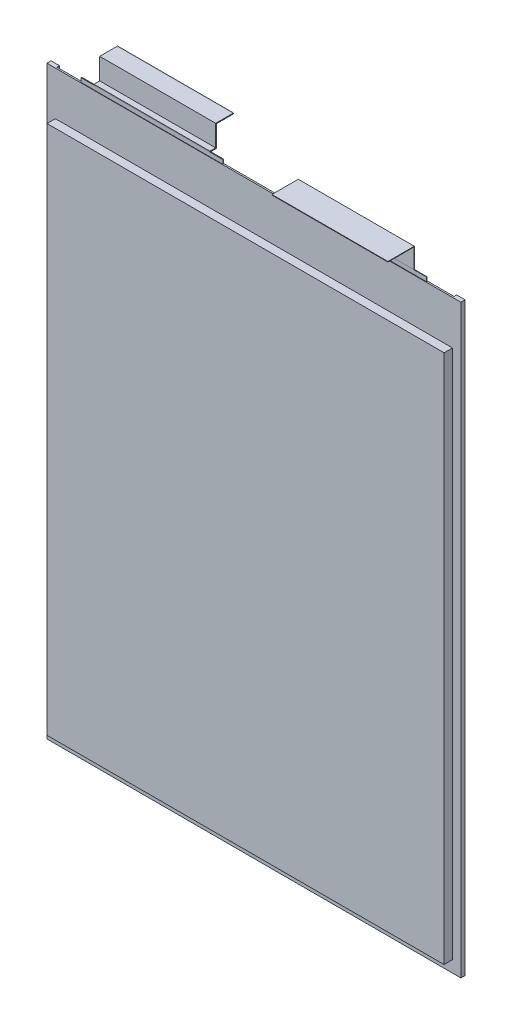
from build123d import *

# Parameters (mm, degrees)
SKETCH1_W                    = 160.6
SKETCH1_H                    = 227
INSULATION_DEPTH             = 0.3
INSULATION_DEPTH_BACK        = 0.3
SKETCH2_W                    = 154
SKETCH2_H                    = 205.5
MAIN_BODY_DEPTH              = 3.55
MAIN_BODY_DEPTH_BACK         = 3.55
SIDE_FOLDS_DEPTH             = 1.016
SKETCH6_W                    = 55
SKETCH6_H                    = 18.6
NEGATIVE_TAB_BASE_DEPTH      = 0.1
NEGATIVE_TAB_BASE_DEPTH_BACK = 0.1
SKETCH7_W                    = 55
SKETCH7_H                    = 18.6
POSITIVE_TAB_BASE_DEPTH      = 0.15
POSITIVE_TAB_BASE_DEPTH_BACK = 0.15
SKETCH113_W                  = 0.2
SKETCH113_H                  = 45
NEGATIVE_TAB_DEPTH           = 31.160222221
SKETCH113_ON_SEGMENT_2_W     = 0.2
SKETCH113_ON_SEGMENT_2_H     = 45
NEGATIVE_TAB_2_DEPTH         = 33.621222221
SKETCH110_W                  = 0.3
SKETCH110_H                  = 45
POSITIVE_TAB_DEPTH           = 23.650499994
SKETCH110_ON_SEGMENT_2_W     = 0.3
SKETCH110_ON_SEGMENT_2_H     = 45
POSITIVE_TAB_2_DEPTH         = 49.236449989
SKETCH110_ON_SEGMENT_3_W     = 0.3
SKETCH110_ON_SEGMENT_3_H     = 45
POSITIVE_TAB_3_DEPTH         = 55.260999989
SKETCH110_ON_SEGMENT_4_W     = 0.3
SKETCH110_ON_SEGMENT_4_H     = 45
POSITIVE_TAB_4_DEPTH         = 31.122574994
SKETCH110_ON_SEGMENT_5_W     = 0.3
SKETCH110_ON_SEGMENT_5_H     = 45
POSITIVE_TAB_5_DEPTH         = 1.15


with BuildPart() as part:
    # Sketch1 → Insulation (new, two sides)
    with BuildSketch(Plane.XY) as insulation_sk:
        Rectangle(SKETCH1_W, SKETCH1_H)
    extrude(amount=INSULATION_DEPTH)
    extrude(insulation_sk.sketch, amount=-INSULATION_DEPTH_BACK)

    # Sketch2 → Main Body (add, two sides)
    with BuildSketch(Plane.XY) as main_body_sk:
        with Locations((0, -6.25)):
            Rectangle(SKETCH2_W, SKETCH2_H)
    extrude(amount=MAIN_BODY_DEPTH)
    extrude(main_body_sk.sketch, amount=-MAIN_BODY_DEPTH_BACK)

    # Sketch5 → Side Folds (add)
    with BuildSketch(Plane(origin=(0, 0, -0.3), x_dir=(-1, 0, 0), z_dir=(0, 0, -1))):
        Polygon((-77, -109), (-77, 96.5), (-77, 113.5), (-80.3, 113.5), (-80.3, -113.5), (-77, -113.5), align=None)
        Polygon((77, 113.5), (77, 96.5), (77, -109), (77, -113.5), (80.3, -113.5), (80.3, 113.5), align=None)
    extrude(amount=SIDE_FOLDS_DEPTH)

    # Sketch6 → Negative Tab Base (add, two sides)
    with BuildSketch(Plane.XY) as negative_tab_base_sk:
        with Locations((39.3, 105.8)):
            Rectangle(SKETCH6_W, SKETCH6_H)
    extrude(amount=NEGATIVE_TAB_BASE_DEPTH)
    extrude(negative_tab_base_sk.sketch, amount=-NEGATIVE_TAB_BASE_DEPTH_BACK)

    # Sketch7 → Positive Tab Base (add, two sides)
    with BuildSketch(Plane.XY) as positive_tab_base_sk:
        with Locations((-39.7, 105.8)):
            Rectangle(SKETCH7_W, SKETCH7_H)
    extrude(amount=POSITIVE_TAB_BASE_DEPTH)
    extrude(positive_tab_base_sk.sketch, amount=-POSITIVE_TAB_BASE_DEPTH_BACK)


with BuildPart() as body_2:
    # Sketch113 → Negative Tab (new body)
    with BuildSketch(Plane(origin=(39.3, 115.1, 0), x_dir=(0, 0, -1), z_dir=(0, 1, 0))):
        Rectangle(SKETCH113_W, SKETCH113_H)
    extrude(amount=NEGATIVE_TAB_DEPTH)

    # Negative Tab mitre 1
    split(bisect_by=Plane(origin=(39.3, 122.76, 0), x_dir=(1, 0, 0), z_dir=(0, -0.707106781, -0.707106781)), keep=Keep.TOP)


with BuildPart() as body_3:
    # Sketch113 on segment 2 (carried to segment 2) → Negative Tab 2 (new body)
    with BuildSketch(Plane(origin=(39.3, 122.76, -23.500222221), x_dir=(0, 1, 0), z_dir=(0, 0, 1))):
        Rectangle(SKETCH113_ON_SEGMENT_2_W, SKETCH113_ON_SEGMENT_2_H)
    extrude(amount=NEGATIVE_TAB_2_DEPTH)

    # Negative Tab 2 mitre 1
    split(bisect_by=Plane(origin=(39.3, 122.76, 0), x_dir=(-1, 0, 0), z_dir=(0, 0.707106781, 0.707106781)), keep=Keep.TOP)


with BuildPart() as body_4:
    # Sketch110 → Positive Tab (new body)
    with BuildSketch(Plane(origin=(-39.7, 115.1, 0), x_dir=(0, 0, -1), z_dir=(0, 1, 0))):
        Rectangle(SKETCH110_W, SKETCH110_H)
    extrude(amount=POSITIVE_TAB_DEPTH)

    # Positive Tab mitre 1
    split(bisect_by=Plane(origin=(-39.7, 115.25, 0), x_dir=(1, 0, 0), z_dir=(0, -0.707106781, 0.707106781)), keep=Keep.TOP)


with BuildPart() as body_5:
    # Sketch110 on segment 2 (carried to segment 2) → Positive Tab 2 (new body)
    with BuildSketch(Plane(origin=(-39.7, 115.25, 23.500499994), x_dir=(0, -1, 0), z_dir=(0, 0, -1))):
        Rectangle(SKETCH110_ON_SEGMENT_2_W, SKETCH110_ON_SEGMENT_2_H)
    extrude(amount=POSITIVE_TAB_2_DEPTH)

    # Positive Tab 2 mitre 1
    split(bisect_by=Plane(origin=(-39.7, 115.25, 0), x_dir=(-1, 0, 0), z_dir=(0, 0.707106781, -0.707106781)), keep=Keep.TOP)

    # Positive Tab 2 mitre 2
    split(bisect_by=Plane(origin=(-39.7, 115.25, -2.23545), x_dir=(1, 0, 0), z_dir=(0, -0.707106781, 0.707106781)), keep=Keep.TOP)


with BuildPart() as body_6:
    # Sketch110 on segment 3 (carried to segment 3) → Positive Tab 3 (new body)
    with BuildSketch(Plane(origin=(-39.7, 91.749500006, -2.23545), x_dir=(0, 0, -1), z_dir=(0, 1, 0))):
        Rectangle(SKETCH110_ON_SEGMENT_3_W, SKETCH110_ON_SEGMENT_3_H)
    extrude(amount=POSITIVE_TAB_3_DEPTH)

    # Positive Tab 3 mitre 1
    split(bisect_by=Plane(origin=(-39.7, 115.25, -2.23545), x_dir=(-1, 0, 0), z_dir=(0, 0.707106781, -0.707106781)), keep=Keep.TOP)

    # Positive Tab 3 mitre 2
    split(bisect_by=Plane(origin=(-39.7, 123.51, -2.23545), x_dir=(1, 0, 0), z_dir=(0, -0.707106781, 0.707106781)), keep=Keep.TOP)


with BuildPart() as body_7:
    # Sketch110 on segment 4 (carried to segment 4) → Positive Tab 4 (new body)
    with BuildSketch(Plane(origin=(-39.7, 123.51, 21.265049994), x_dir=(0, -1, 0), z_dir=(0, 0, -1))):
        Rectangle(SKETCH110_ON_SEGMENT_4_W, SKETCH110_ON_SEGMENT_4_H)
    extrude(amount=POSITIVE_TAB_4_DEPTH)

    # Positive Tab 4 mitre 1
    split(bisect_by=Plane(origin=(-39.7, 123.51, -2.23545), x_dir=(-1, 0, 0), z_dir=(0, 0.707106781, -0.707106781)), keep=Keep.TOP)

    # Positive Tab 4 mitre 2
    split(bisect_by=Plane(origin=(-39.7, 123.51, -8.857525), x_dir=(0, -1, 0), z_dir=(0, 0, 1)), keep=Keep.TOP)


with BuildPart() as body_8:
    # Sketch110 on segment 5 (carried to segment 5) → Positive Tab 5 (new body)
    with BuildSketch(Plane(origin=(-39.7, 123.51, -7.857525), x_dir=(0, -1, 0), z_dir=(0, 0, -1))):
        Rectangle(SKETCH110_ON_SEGMENT_5_W, SKETCH110_ON_SEGMENT_5_H)
    extrude(amount=POSITIVE_TAB_5_DEPTH)

    # Positive Tab 5 mitre 1
    split(bisect_by=Plane(origin=(-39.7, 123.51, -8.857525), x_dir=(0, 1, 0), z_dir=(0, 0, -1)), keep=Keep.TOP)


solid = Compound([part.part, body_2.part, body_3.part, body_4.part, body_5.part, body_6.part, body_7.part, body_8.part])
